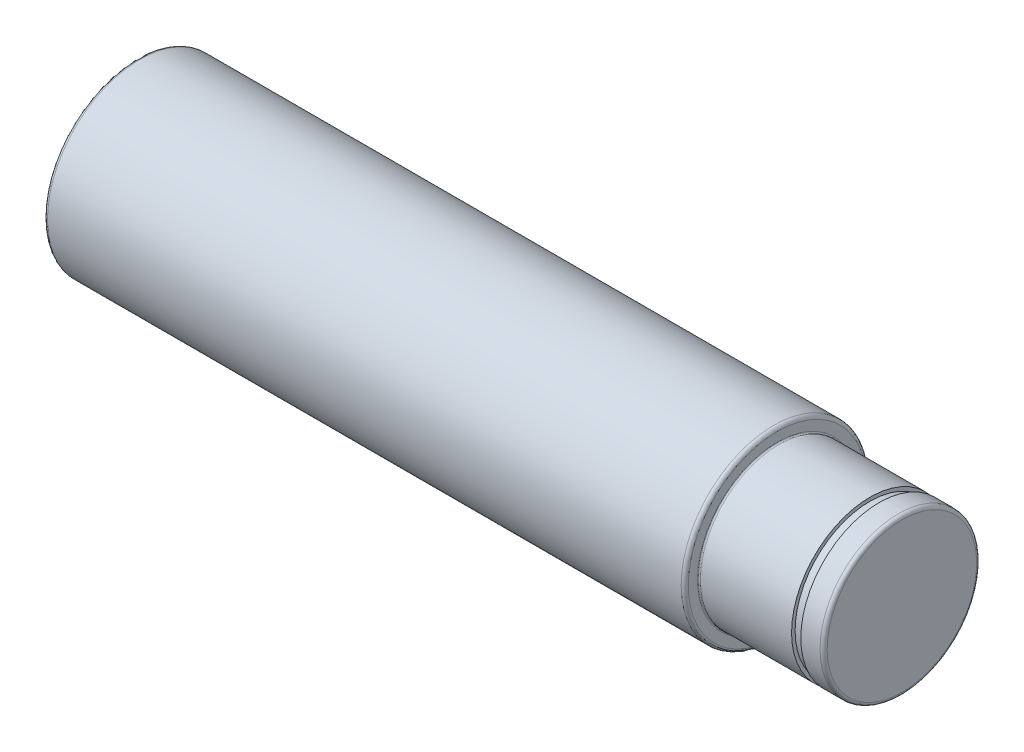
from build123d import *


with BuildPart() as part:
    # Sketch1 → Revolve1 (revolve)
    with BuildSketch(Plane.XY):
        with BuildLine():
            Line((0, 0), (0, 12.5))
            ThreePointArc((0, 12.5), (0.146446609, 12.853553391), (0.5, 13))
            Line((0.5, 13), (89.5, 13))
            ThreePointArc((89.5, 13), (89.853553391, 12.853553391), (90, 12.5))
            Line((90, 12.5), (90, 11.2))
            ThreePointArc((90, 11.2), (90.058578644, 11.058578644), (90.2, 11))
            Line((90.2, 11), (103, 11))
            Line((103, 11), (103, 10.5))
            Line((103, 10.5), (104.3, 10.5))
            Line((104.3, 10.5), (104.3, 11))
            Line((104.3, 11), (107, 11))
            ThreePointArc((107, 11), (107.353553391, 10.853553391), (107.5, 10.5))
            Line((107.5, 10.5), (107.5, 0))
            Line((107.5, 0), (0, 0))
        make_face()
    revolve(axis=Axis((0, 0, 0), (1, 0, 0)))


solid = part.part
